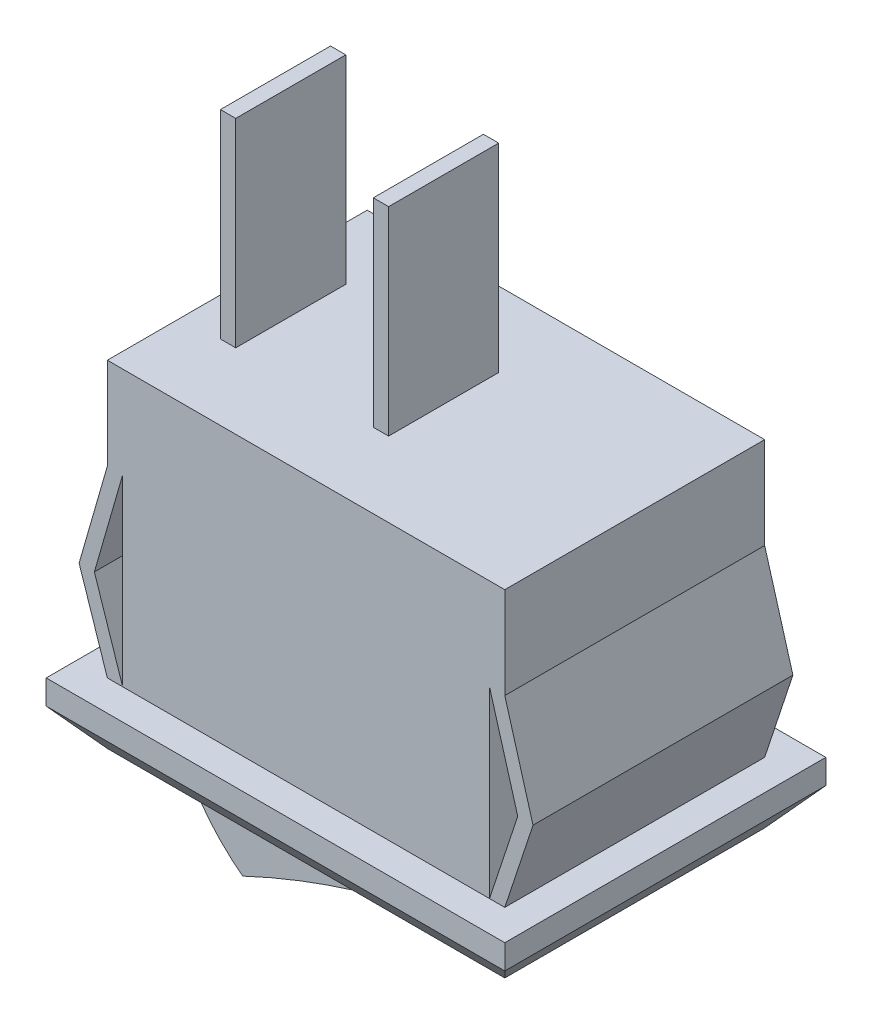
from build123d import *

# Parameters (mm, degrees)
SKETCH_1_W          = 15
SKETCH_1_H          = 10.5
EXTRUDE_1_DEPTH     = 0.8
SKETCH_2_W          = 13
SKETCH_2_H          = 8.5
EXTRUDE_2_DEPTH     = 4.25
EXTRUDE_4_DEPTH     = 8.5
SKETCH_5_W          = 0.5
SKETCH_5_H          = 3.6
EXTRUDE_5_DEPTH     = 6.5
SKETCH_6_W          = 11
SKETCH_6_H          = 6.5
CUT_EXTRUDE_1_DEPTH = 1
EXTRUDE_6_DEPTH     = 3.15


with BuildPart() as part:
    # 草图1 → 凸台-拉伸1 (new body)
    with BuildSketch(Plane(origin=(0, 0, 0), x_dir=(1, 0, 0), z_dir=(0, 1, 0))):
        Rectangle(SKETCH_1_W, SKETCH_1_H)
    extrude(amount=EXTRUDE_1_DEPTH)

    # 草图2 → section 0 of loft_1
    with BuildSketch(Plane(origin=(0, -1.2, 0), x_dir=(-1, 0, 0), z_dir=(0, -1, 0)), mode=Mode.PRIVATE) as loft_1_s0:
        Rectangle(SKETCH_2_W, SKETCH_2_H)
    # loft up to a face of the part (loft_1)
    loft([loft_1_s0.sketch, part.faces().sort_by_distance((0, 0, 0))[0]])

    # 草图3 → 凸台-拉伸2 (add, symmetric)
    with BuildSketch(Plane.XY):
        Polygon((6.5, 9.8), (-6.5, 9.8), (-6.5, 6.8), (-6, 6.8), (-6, 0.8), (6, 0.8), (6, 6.8), (6.5, 6.8), align=None)
    extrude(amount=EXTRUDE_2_DEPTH, both=True)

    # 草图4 → 凸台-拉伸4 (add)
    with BuildSketch(Plane(origin=(0, 0, -4.25), x_dir=(-1, 0, 0), z_dir=(0, 0, -1))):
        Polygon((6.5, 6.8), (7.423732472, 3.591094946), (6.5, 0.8), (6, 0.8), (6.923732472, 3.591094946), (6, 6.8), align=None)
        Polygon((-6, 6.8), (-6.5, 6.8), (-7.423732472, 3.591094946), (-6.5, 0.8), (-6, 0.8), (-6.923732472, 3.591094946), align=None)
    extrude(amount=-EXTRUDE_4_DEPTH)

    # 草图5 → 凸台-拉伸5 (add)
    with BuildSketch(Plane(origin=(0, 9.8, 0), x_dir=(1, 0, 0), z_dir=(0, 1, 0))):
        Rectangle(SKETCH_5_W, SKETCH_5_H)
        with Locations((-5, 0)):
            Rectangle(SKETCH_5_W, SKETCH_5_H)
    extrude(amount=EXTRUDE_5_DEPTH)

    # 草图6 → 切除-拉伸1 (cut)
    with BuildSketch(Plane(origin=(0, -1.2, 0), x_dir=(-1, 0, 0), z_dir=(0, -1, 0))):
        Rectangle(SKETCH_6_W, SKETCH_6_H)
    extrude(amount=-CUT_EXTRUDE_1_DEPTH, mode=Mode.SUBTRACT)

    # 草图7 → 凸台-拉伸6 (add, symmetric)
    with BuildSketch(Plane.XY):
        with BuildLine():
            Line((-5.5, -0.2), (5.5, -0.2))
            Line((5.5, -0.2), (5.5, -1.2))
            ThreePointArc((5.5, -1.2), (1.062510248, -2.101360111), (-3.174011421, -3.7))
            ThreePointArc((-3.174011421, -3.7), (-4.635468683, -2.14834899), (-5.5, -0.2))
        make_face()
    extrude(amount=EXTRUDE_6_DEPTH, both=True)


solid = part.part
